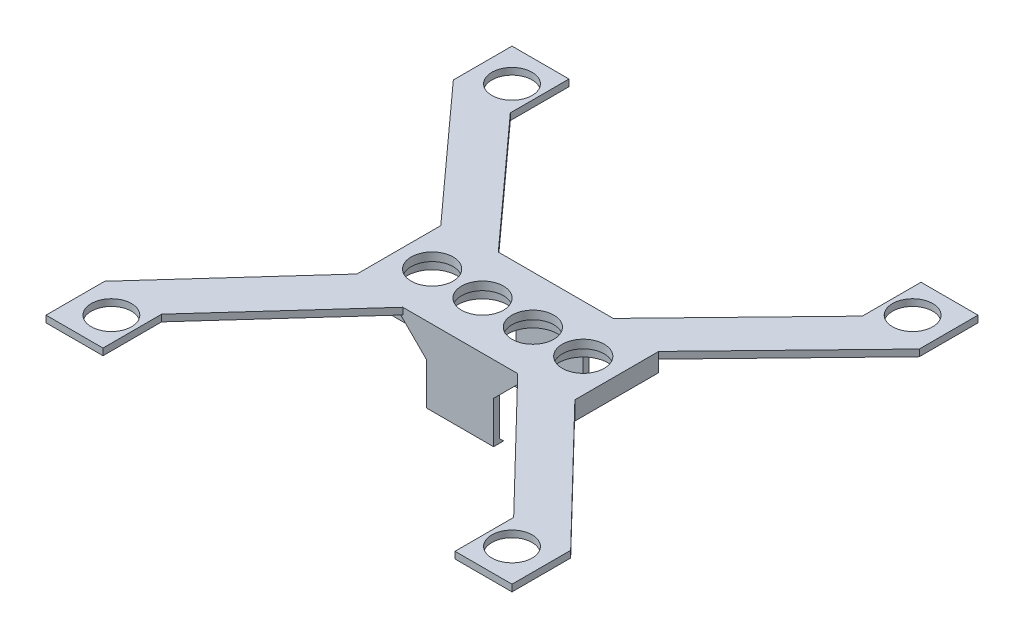
from build123d import *

# Parameters (mm, degrees)
SKICA1_W                 = 26
SKICA1_H                 = 1
P_IDAT_VYSUNUT_M1_DEPTH  = 10
SKICA2_R                 = 2.5
ODEBRAT_VYSUNUT_M1_DEPTH = 1
SKICA3_R                 = 2.4
P_IDAT_VYSUNUT_M2_DEPTH  = 0.8
SKICA4_W                 = 26
SKICA4_H                 = 10
SKICA4_R                 = 3
P_IDAT_VYSUNUT_M3_DEPTH  = 1.2
SKICA6_W                 = 8
SKICA6_H                 = 0.7
P_IDAT_VYSUNUT_M5_DEPTH  = 9
P_IDAT_VYSUNUT_M6_DEPTH  = 8
P_IDAT_VYSUNUT_M8_DEPTH  = 0.7
P_IDAT_VYSUNUT_M9_DEPTH  = 0.7


with BuildPart() as part:
    # Skica1 → Přidat vysunutím1 (new body)
    with BuildSketch(Plane.XY):
        with Locations((-39.156744291, -7.214704976)):
            Rectangle(SKICA1_W, SKICA1_H)
    extrude(amount=P_IDAT_VYSUNUT_M1_DEPTH)

    # Skica2 → Odebrat vysunutím1 (cut)
    with BuildSketch(Plane(origin=(0, -7.714704976, 0), x_dir=(-1, 0, 0), z_dir=(0, -1, 0))):
        with Locations((48.186744291, -5)):
            Circle(SKICA2_R)
        with Locations((42.176744291, -5)):
            Circle(SKICA2_R)
        with Locations((36.166744291, -5)):
            Circle(SKICA2_R)
        with Locations((30.156744291, -5)):
            Circle(SKICA2_R)
    extrude(amount=-ODEBRAT_VYSUNUT_M1_DEPTH, mode=Mode.SUBTRACT)

    # Skica3 → Přidat vysunutím2 (add)
    with BuildSketch(Plane(origin=(0, -6.714704976, 0), x_dir=(1, 0, 0), z_dir=(0, 1, 0))):
        Polygon((-32.956744291, 0), (-17.656744291, 15.8), (-17.656744291, 22.8), (-10.856744291, 22.8), (-10.856744291, 15.8), (-26.156744291, 0), align=None)
        with Locations((-14.756744291, 18.9)):
            Circle(SKICA3_R, mode=Mode.SUBTRACT)
        Polygon((-52.156744291, 0), (-45.356744291, 0), (-59.656744291, 15.8), (-59.656744291, 22.8), (-66.456744291, 22.8), (-66.456744291, 15.8), align=None)
        with Locations((-62.556744291, 18.9)):
            Circle(SKICA3_R, mode=Mode.SUBTRACT)
        Polygon((-45.356744291, -10), (-59.656744291, -25.8), (-59.656744291, -32.8), (-66.456744291, -32.8), (-66.456744291, -25.8), (-52.156744291, -10), align=None)
        with Locations((-62.556744291, -28.9)):
            Circle(SKICA3_R, mode=Mode.SUBTRACT)
        Polygon((-26.156744291, -10), (-32.956744291, -10), (-17.656744291, -25.8), (-17.656744291, -32.8), (-10.856744291, -32.8), (-10.856744291, -25.8), align=None)
        with Locations((-14.756744291, -28.9)):
            Circle(SKICA3_R, mode=Mode.SUBTRACT)
    extrude(amount=-P_IDAT_VYSUNUT_M2_DEPTH)

    # Skica4 → Přidat vysunutím3 (add)
    with BuildSketch(Plane(origin=(0, -7.714704976, 0), x_dir=(-1, 0, 0), z_dir=(0, -1, 0))):
        with Locations((39.156744291, -5)):
            Rectangle(SKICA4_W, SKICA4_H)
        with Locations((48.186744291, -5)):
            Circle(SKICA4_R, mode=Mode.SUBTRACT)
        with Locations((42.176744291, -5)):
            Circle(SKICA4_R, mode=Mode.SUBTRACT)
        with Locations((36.166744291, -5)):
            Circle(SKICA4_R, mode=Mode.SUBTRACT)
        with Locations((30.156744291, -5)):
            Circle(SKICA4_R, mode=Mode.SUBTRACT)
    extrude(amount=P_IDAT_VYSUNUT_M3_DEPTH)

    # Skica6 → Přidat vysunutím5 (add)
    with BuildSketch(Plane(origin=(0, -6.714704976, 0), x_dir=(1, 0, 0), z_dir=(0, 1, 0))):
        with Locations((-39.156744291, 0.35)):
            Rectangle(SKICA6_W, SKICA6_H)
        with Locations((-39.156744291, -10.35)):
            Rectangle(SKICA6_W, SKICA6_H)
    extrude(amount=-P_IDAT_VYSUNUT_M5_DEPTH)

    # Skica7 → Přidat vysunutím6 (add)
    with BuildSketch(Plane(origin=(-35.156744291, 0, 0), x_dir=(0, 0, -1), z_dir=(1, 0, 0))):
        Polygon((-10, -15.714704976), (-9.5, -15.714704976), (-10, -15.214704976), align=None)
        Polygon((0, -15.714704976), (0, -15.214704976), (-0.5, -15.714704976), align=None)
    extrude(amount=-P_IDAT_VYSUNUT_M6_DEPTH)

    # Skica8 → Přidat vysunutím8 (add)
    with BuildSketch(Plane(origin=(0, 0, 0), x_dir=(-1, 0, 0), z_dir=(0, 0, -1))):
        Polygon((43.156744291, -6.714704976), (43.156744291, -10.714704976), (47.156744291, -6.714704976), align=None)
        Polygon((35.156744291, -10.714704976), (35.156744291, -6.714704976), (31.156744291, -6.714704976), align=None)
    extrude(amount=P_IDAT_VYSUNUT_M8_DEPTH)

    # Skica9 → Přidat vysunutím9 (add)
    with BuildSketch(Plane.XY.offset(10)):
        Polygon((-43.156744291, -6.714704976), (-47.156744291, -6.714704976), (-43.156744291, -10.714704976), align=None)
        Polygon((-35.156744291, -6.714704976), (-35.156744291, -10.714704976), (-31.156744291, -6.714704976), align=None)
    extrude(amount=P_IDAT_VYSUNUT_M9_DEPTH)


solid = part.part
